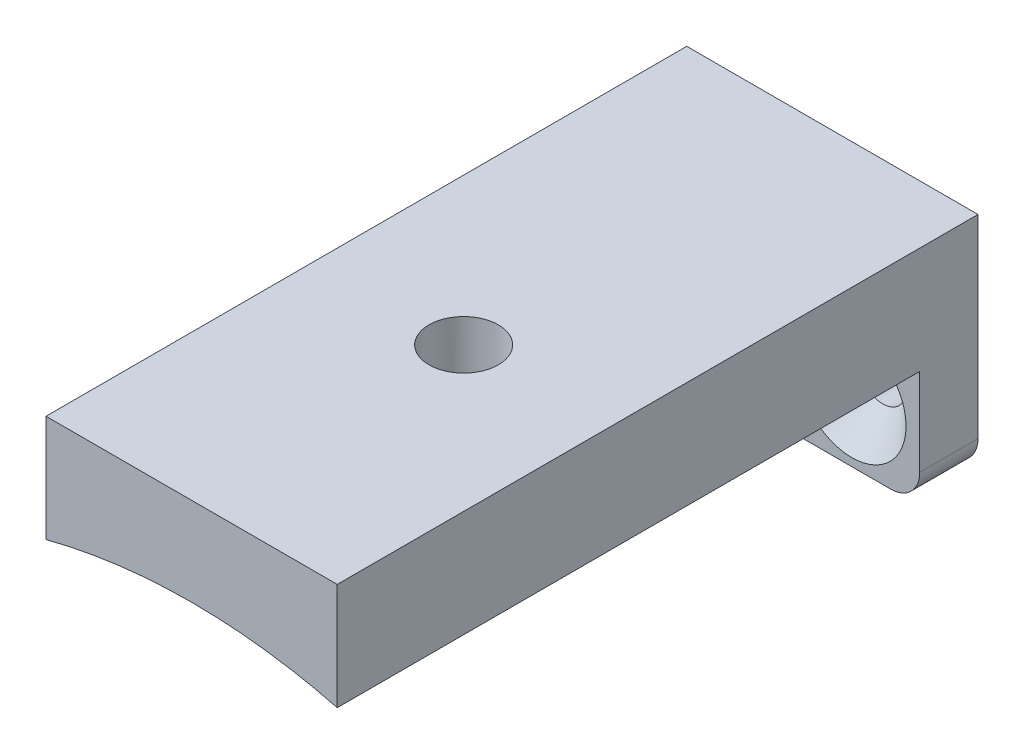
from build123d import *

# Parameters (mm, degrees)
AUFSATZ_LINEAR_AUSTRAGEN1_DEPTH                      = 6
FORMSENKUNG_F_R_M4_SENKSCHRAUBE_MIT_INNE_D           = 4.8
FORMSENKUNG_F_R_M4_SENKSCHRAUBE_MIT_INNE_CSINK_D     = 11.18
FORMSENKUNG_F_R_M4_SENKSCHRAUBE_MIT_INNE_CSINK_ANGLE = 90
AUFSATZ_LINEAR_AUSTRAGEN2_DEPTH                      = 60
AUFSATZ_LINEAR_AUSTRAGEN2_DEPTH_BACK                 = 6
STIRNSENKUNG_F_R_1_4_FLACHKOPFSCHRAUBE_D             = 7.14248
STIRNSENKUNG_F_R_1_4_FLACHKOPFSCHRAUBE_CBORE_D       = 11.90752
STIRNSENKUNG_F_R_1_4_FLACHKOPFSCHRAUBE_CBORE_DEPTH   = 0.500000016


with BuildPart() as part:
    # Skizze1 → Aufsatz-Linear austragen1 (new body)
    with BuildSketch(Plane.XY):
        with BuildLine():
            Line((-15, 12), (-15, 3))
            ThreePointArc((-15, 3), (-14.121320344, 0.878679656), (-12, 0))
            Line((-12, 0), (12, 0))
            ThreePointArc((12, 0), (14.121320344, 0.878679656), (15, 3))
            Line((15, 3), (15, 12))
            ThreePointArc((15, 12), (0, 13.905249807), (-15, 12))
        make_face()
    extrude(amount=AUFSATZ_LINEAR_AUSTRAGEN1_DEPTH)

    # Formsenkung für M4 Senkschraube mit Innensechskant1 (through all)
    with Locations(Plane.XY.offset(6)):
        with Locations((-8, 6.4), (8, 6.4)):
            CounterSinkHole(FORMSENKUNG_F_R_M4_SENKSCHRAUBE_MIT_INNE_D / 2, FORMSENKUNG_F_R_M4_SENKSCHRAUBE_MIT_INNE_CSINK_D / 2, counter_sink_angle=FORMSENKUNG_F_R_M4_SENKSCHRAUBE_MIT_INNE_CSINK_ANGLE)

    # Skizze4 → Aufsatz-Linear austragen2 (add, two sides)
    with BuildSketch(Plane.XY.offset(6)) as aufsatz_linear_austragen2_sk:
        with BuildLine():
            Line((-15, 12), (-15, 23))
            Line((-15, 23), (15, 23))
            Line((15, 23), (15, 12))
            ThreePointArc((15, 12), (0, 13.905249807), (-15, 12))
        make_face()
    extrude(amount=AUFSATZ_LINEAR_AUSTRAGEN2_DEPTH)
    extrude(aufsatz_linear_austragen2_sk.sketch, amount=-AUFSATZ_LINEAR_AUSTRAGEN2_DEPTH_BACK)

    # Stirnsenkung für 1/4 Flachkopfschraube (Kopf Button)1 (through all)
    with Locations(Plane(origin=(0.121475485, 13.905126838, 38.119269102), x_dir=(-0.999997951, 0.002024591, 0), z_dir=(-0.002024591, -0.999997951, 0))):
        with Locations((0, 0)):
            CounterBoreHole(STIRNSENKUNG_F_R_1_4_FLACHKOPFSCHRAUBE_D / 2, STIRNSENKUNG_F_R_1_4_FLACHKOPFSCHRAUBE_CBORE_D / 2, STIRNSENKUNG_F_R_1_4_FLACHKOPFSCHRAUBE_CBORE_DEPTH)


solid = part.part
